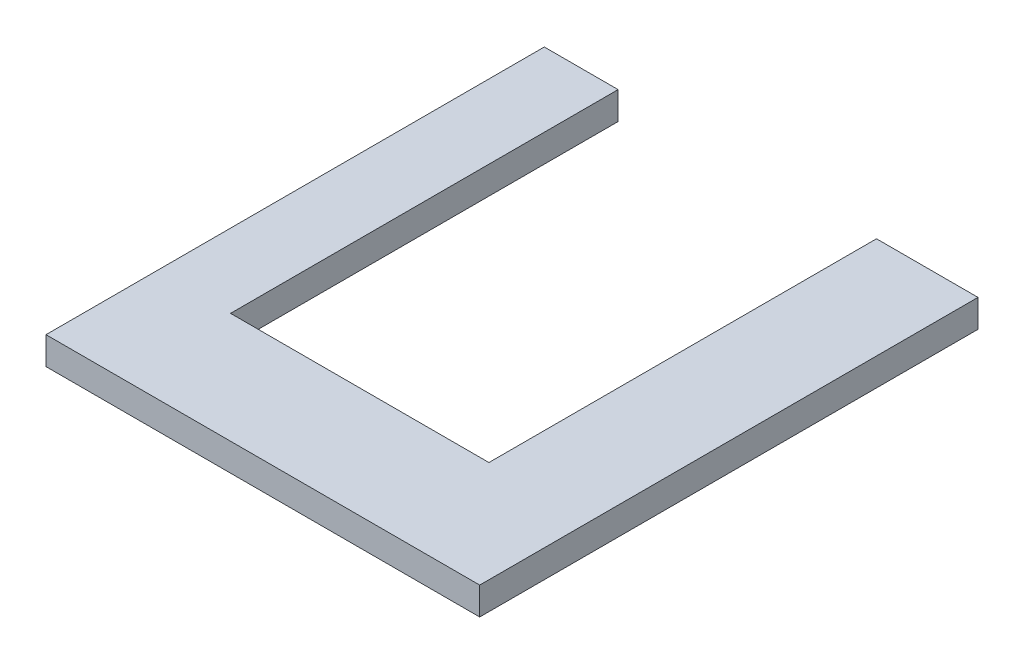
from build123d import *

# Parameters (mm, degrees)
ESBO_O1_W                = 2350
ESBO_O1_H                = 150
RESSALTO_EXTRUS_O1_DEPTH = 2700
ESBO_O2_W                = 1400
ESBO_O2_H                = 2100
CORTE_EXTRUS_O1_DEPTH    = 151


with BuildPart() as part:
    # Esboço1 → Ressalto-extrusão1 (new body)
    with BuildSketch(Plane.XY):
        with Locations((1175, 75)):
            Rectangle(ESBO_O1_W, ESBO_O1_H)
    extrude(amount=RESSALTO_EXTRUS_O1_DEPTH)

    # Esboço2 → Corte-extrusão1 (cut, through all)
    with BuildSketch(Plane(origin=(0, 150, 0), x_dir=(1, 0, 0), z_dir=(0, 1, 0))):
        with Locations((1100, -1050)):
            Rectangle(ESBO_O2_W, ESBO_O2_H)
    extrude(amount=-CORTE_EXTRUS_O1_DEPTH, mode=Mode.SUBTRACT)


solid = part.part
